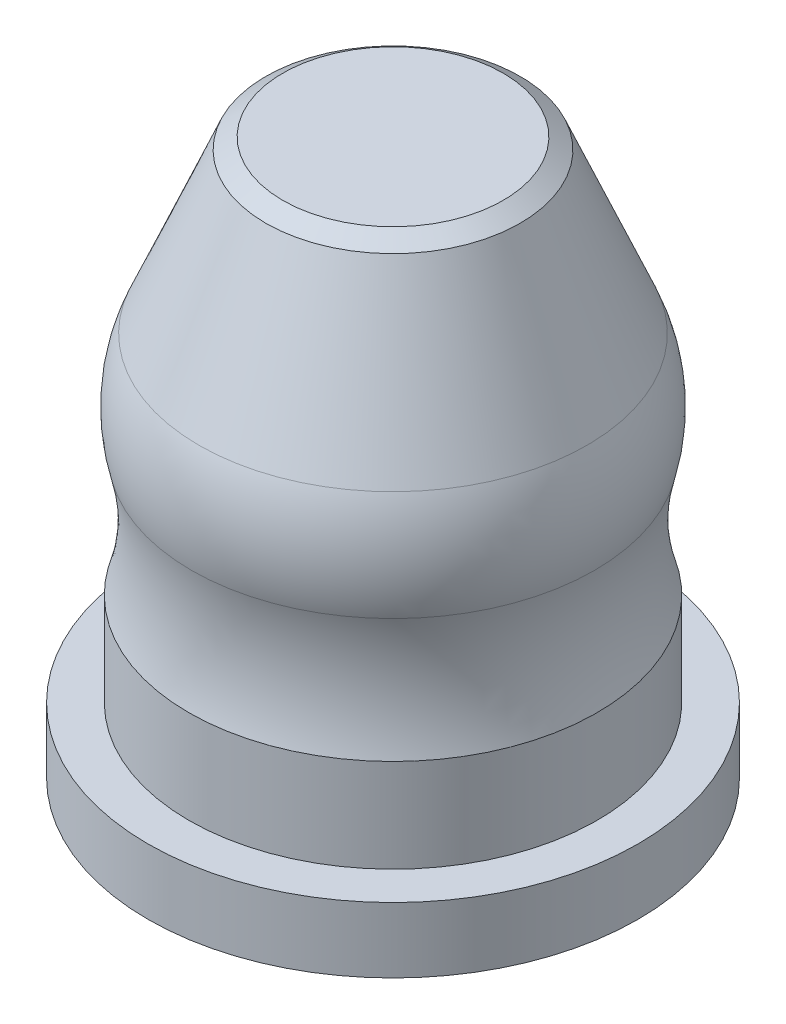
from build123d import *

# Parameters (mm, degrees)
SKETCH2_R           = 30
BOSS_EXTRUDE1_DEPTH = 8


with BuildPart() as part:
    # Sketch1 → Revolve1 (revolve)
    with BuildSketch(Plane.XY):
        with BuildLine():
            Line((0, 0), (25, 0))
            Line((25, 0), (25, 11.42377433))
            ThreePointArc((25, 11.42377433), (23.792992012, 18.861807529), (24.672326333, 26.345655289))
            ThreePointArc((24.672326333, 26.345655289), (25.273083835, 32.826746989), (23.760908087, 39.157527645))
            Line((23.760908087, 39.157527645), (15.581247413, 58.617194357))
            Line((15.581247413, 58.617194357), (13.5, 60))
            Line((13.5, 60), (0, 60))
            Line((0, 60), (0, 0))
        make_face()
    revolve(axis=Axis((0, 0, 0), (0, -1, 0)))

    # Sketch2 → Boss-Extrude1 (add)
    with BuildSketch(Plane.XZ):
        Circle(SKETCH2_R)
    extrude(amount=BOSS_EXTRUDE1_DEPTH)


solid = part.part
